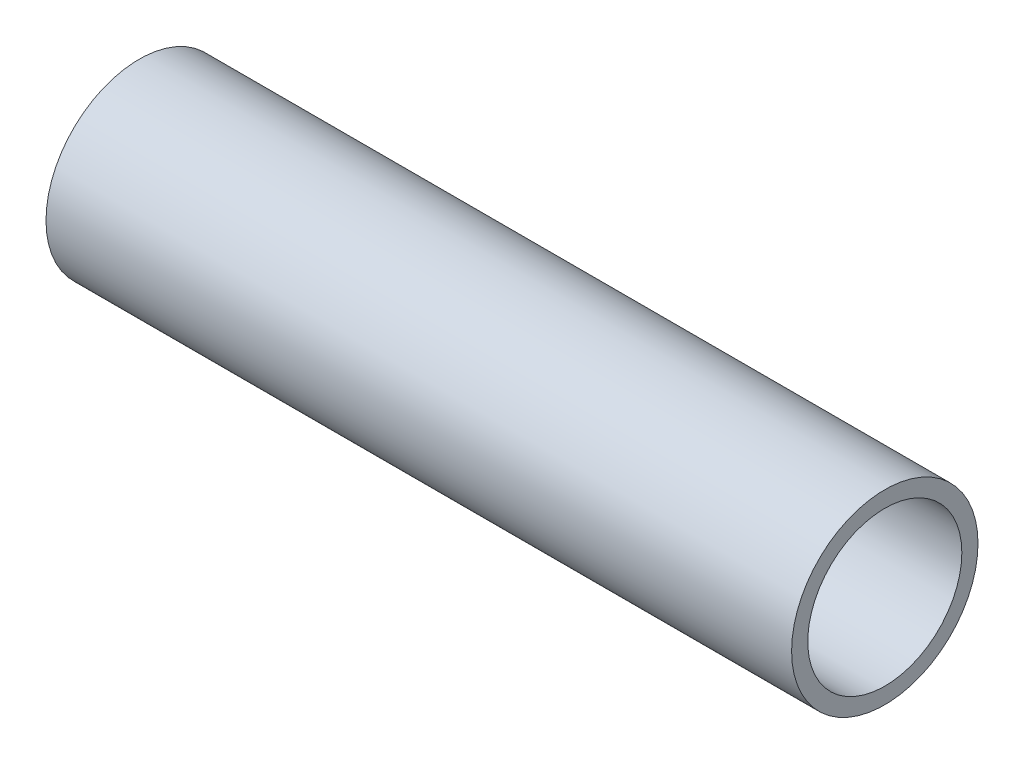
from build123d import *

# Parameters (mm, degrees)
SKETCH1_R           = 9.525
SKETCH1_R_2         = 7.874
BOSS_EXTRUDE1_DEPTH = 38.1


with BuildPart() as part:
    # Sketch1 → Boss-Extrude1 (new body, symmetric)
    with BuildSketch(Plane(origin=(0, 0, 0), x_dir=(0, 0, -1), z_dir=(1, 0, 0))):
        Circle(SKETCH1_R)
        Circle(SKETCH1_R_2, mode=Mode.SUBTRACT)
    extrude(amount=BOSS_EXTRUDE1_DEPTH, both=True)


solid = part.part
